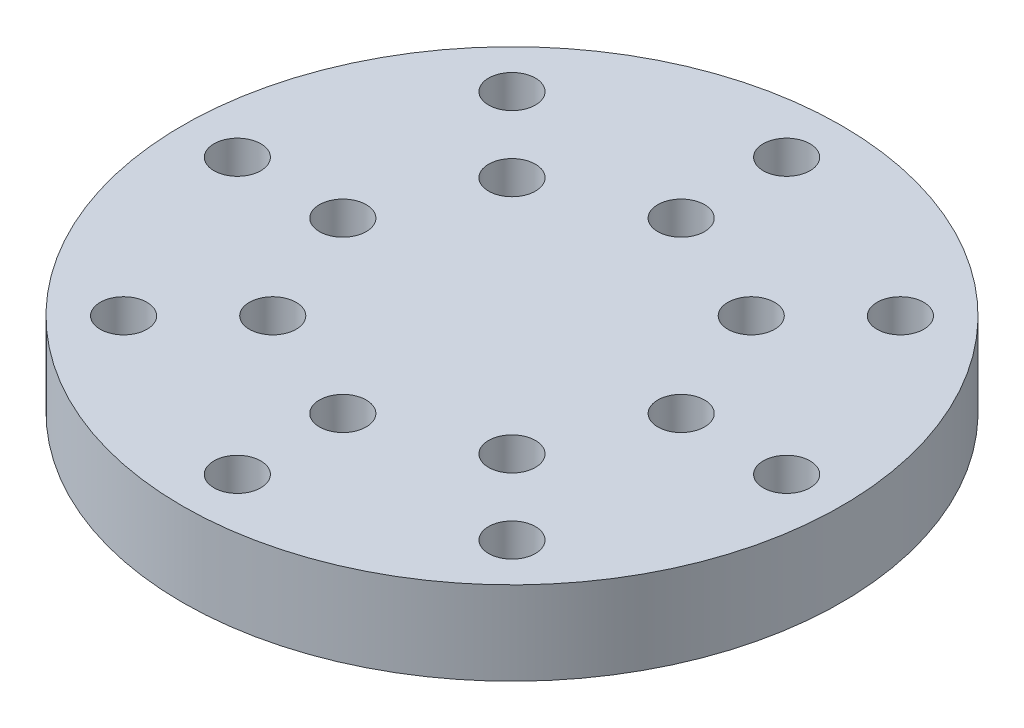
from build123d import *

# Parameters (mm, degrees)
SKETCH1_R                       = 19.05
BOSS_EXTRUDE1_DEPTH             = 4.826
M2_5_CLEARANCE_HOLE2_AT_2_COUNT = 2
M2_5_CLEARANCE_HOLE2_AT_2_PITCH = 6.096
CIRPATTERN1_COUNT               = 8


with BuildPart() as part:
    # Sketch1 → Boss-Extrude1 (new body)
    with BuildSketch(Plane(origin=(0, 0, 0), x_dir=(1, 0, 0), z_dir=(0, 1, 0))):
        Circle(SKETCH1_R)
    extrude(amount=BOSS_EXTRUDE1_DEPTH)

    # Sketch11 → M2.5 Clearance Hole2 (revolve, cut)
    with BuildSketch(Plane(origin=(0, 0, -15.875), x_dir=(0, 0, -1), z_dir=(1, 0, 0))):
        Polygon((0, 0), (0, 5.89269403), (1.35255, 5.08), (1.35255, 0), align=None)
    m2_5_clearance_hole2 = revolve(axis=Axis((0, -6.35, -15.875), (0, 1, 0)), mode=Mode.SUBTRACT)

    # M2.5 Clearance Hole2 at 2: M2.5 Clearance Hole2 ×2
    with Locations(*[(0, 0, i * M2_5_CLEARANCE_HOLE2_AT_2_PITCH) for i in range(1, M2_5_CLEARANCE_HOLE2_AT_2_COUNT)]):
        add(m2_5_clearance_hole2, mode=Mode.SUBTRACT)

    # CirPattern1: M2.5 Clearance Hole2 ×8 about axis
    cirpattern1_axis = Axis((0, 0, 0), (0, 1, 0))
    for i in range(1, CIRPATTERN1_COUNT):
        add(m2_5_clearance_hole2.rotate(cirpattern1_axis, i * 360 / CIRPATTERN1_COUNT), mode=Mode.SUBTRACT)

    # CirPattern1 copy 1 sketch → CirPattern1 copy 1 (revolve, cut)
    with BuildSketch(Plane(origin=(-6.914797213, 0, -6.914797213), x_dir=(-0.707106781, 0, -0.707106781), z_dir=(0.707106781, 0, -0.707106781))):
        Polygon((0, 0), (0, 5.89269403), (1.35255, 5.08), (1.35255, 0), align=None)
    revolve(axis=Axis((-6.914797213, -6.35, -6.914797213), (0, 1, 0)), mode=Mode.SUBTRACT)

    # CirPattern1 copy 2 sketch → CirPattern1 copy 2 (revolve, cut)
    with BuildSketch(Plane(origin=(-9.779, 0, 0), x_dir=(-1, 0, 0), z_dir=(0, 0, -1))):
        Polygon((0, 0), (0, 5.89269403), (1.35255, 5.08), (1.35255, 0), align=None)
    revolve(axis=Axis((-9.779, -6.35, 0), (0, 1, 0)), mode=Mode.SUBTRACT)

    # CirPattern1 copy 3 sketch → CirPattern1 copy 3 (revolve, cut)
    with BuildSketch(Plane(origin=(-6.914797213, 0, 6.914797213), x_dir=(-0.707106781, 0, 0.707106781), z_dir=(-0.707106781, 0, -0.707106781))):
        Polygon((0, 0), (0, 5.89269403), (1.35255, 5.08), (1.35255, 0), align=None)
    revolve(axis=Axis((-6.914797213, -6.35, 6.914797213), (0, 1, 0)), mode=Mode.SUBTRACT)

    # CirPattern1 copy 4 sketch → CirPattern1 copy 4 (revolve, cut)
    with BuildSketch(Plane(origin=(0, 0, 9.779), x_dir=(0, 0, 1), z_dir=(-1, 0, 0))):
        Polygon((0, 0), (0, 5.89269403), (1.35255, 5.08), (1.35255, 0), align=None)
    revolve(axis=Axis((0, -6.35, 9.779), (0, 1, 0)), mode=Mode.SUBTRACT)

    # CirPattern1 copy 5 sketch → CirPattern1 copy 5 (revolve, cut)
    with BuildSketch(Plane(origin=(6.914797213, 0, 6.914797213), x_dir=(0.707106781, 0, 0.707106781), z_dir=(-0.707106781, 0, 0.707106781))):
        Polygon((0, 0), (0, 5.89269403), (1.35255, 5.08), (1.35255, 0), align=None)
    revolve(axis=Axis((6.914797213, -6.35, 6.914797213), (0, 1, 0)), mode=Mode.SUBTRACT)

    # CirPattern1 copy 6 sketch → CirPattern1 copy 6 (revolve, cut)
    with BuildSketch(Plane(origin=(9.779, 0, 0), x_dir=(1, 0, 0), z_dir=(0, 0, 1))):
        Polygon((0, 0), (0, 5.89269403), (1.35255, 5.08), (1.35255, 0), align=None)
    revolve(axis=Axis((9.779, -6.35, 0), (0, 1, 0)), mode=Mode.SUBTRACT)

    # CirPattern1 copy 7 sketch → CirPattern1 copy 7 (revolve, cut)
    with BuildSketch(Plane(origin=(6.914797213, 0, -6.914797213), x_dir=(0.707106781, 0, -0.707106781), z_dir=(0.707106781, 0, 0.707106781))):
        Polygon((0, 0), (0, 5.89269403), (1.35255, 5.08), (1.35255, 0), align=None)
    revolve(axis=Axis((6.914797213, -6.35, -6.914797213), (0, 1, 0)), mode=Mode.SUBTRACT)


solid = part.part
